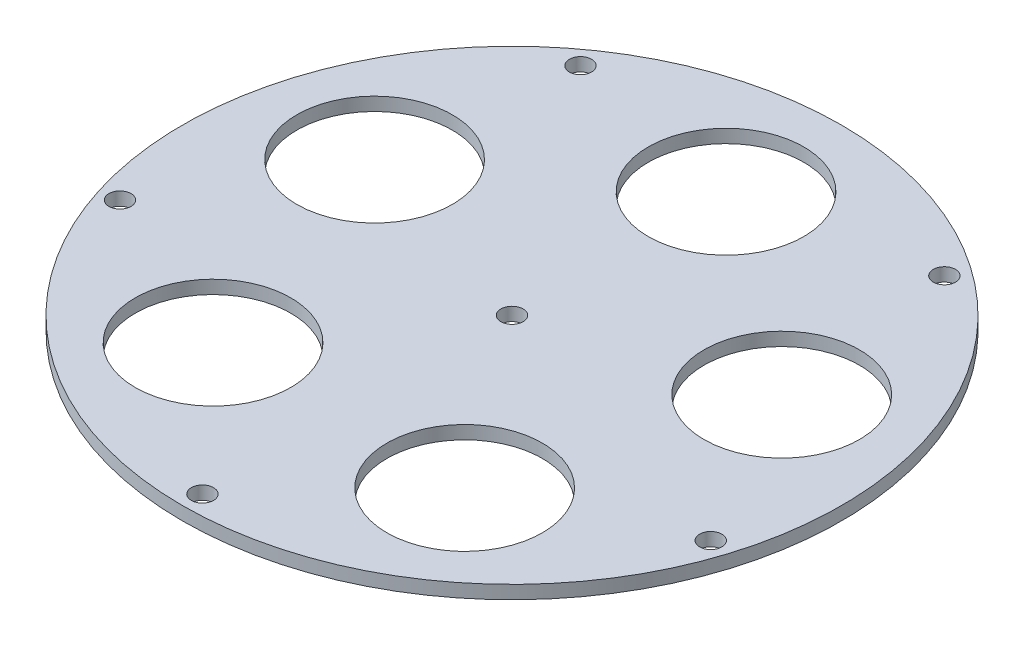
from build123d import *

# Parameters (mm, degrees)
SKETCH1_R           = 74.18267629
BOSS_EXTRUDE2_DEPTH = 3
SKETCH1_4_R         = 17.5
CUT_EXTRUDE1_DEPTH  = 4
SKETCH1_5_R         = 2.5
CUT_EXTRUDE2_DEPTH  = 4
SKETCH1_10_R        = 2.5
CUT_EXTRUDE5_DEPTH  = 10


with BuildPart() as part:
    # Sketch1 → Boss-Extrude2 (new body)
    with BuildSketch(Plane(origin=(0, 0, 0), x_dir=(1, 0, 0), z_dir=(0, 1, 0))):
        Circle(SKETCH1_R)
    extrude(amount=-BOSS_EXTRUDE2_DEPTH)

    # Sketch1_4 → Cut-Extrude1 (cut)
    with BuildSketch(Plane(origin=(0, 0, 0), x_dir=(1, 0, 0), z_dir=(0, 1, 0))):
        with Locations((0, 48.18267629)):
            Circle(SKETCH1_4_R)
        with Locations((45.824448258, 14.889265808)):
            Circle(SKETCH1_4_R)
        with Locations((28.321066539, -38.980603953)):
            Circle(SKETCH1_4_R)
        with Locations((-28.321066539, -38.980603953)):
            Circle(SKETCH1_4_R)
        with Locations((-45.824448258, 14.889265808)):
            Circle(SKETCH1_4_R)
    extrude(amount=-CUT_EXTRUDE1_DEPTH, mode=Mode.SUBTRACT)

    # Sketch1_5 → Cut-Extrude2 (cut)
    with BuildSketch(Plane(origin=(0, 0, 0), x_dir=(1, 0, 0), z_dir=(0, 1, 0))):
        with Locations((40.958449464, 56.374469332)):
            Circle(SKETCH1_5_R)
        with Locations((66.272163358, -21.533131187)):
            Circle(SKETCH1_5_R)
        with Locations((0, -69.68267629)):
            Circle(SKETCH1_5_R)
        with Locations((-66.605033139, -21.641287135)):
            Circle(SKETCH1_5_R)
        with Locations((-40.958449464, 56.374469332)):
            Circle(SKETCH1_5_R)
    extrude(amount=-CUT_EXTRUDE2_DEPTH, mode=Mode.SUBTRACT)

    # Sketch1_10 → Cut-Extrude5 (cut)
    with BuildSketch(Plane(origin=(0, 0, 0), x_dir=(1, 0, 0), z_dir=(0, 1, 0))):
        Circle(SKETCH1_10_R)
    extrude(amount=-CUT_EXTRUDE5_DEPTH, mode=Mode.SUBTRACT)


solid = part.part
